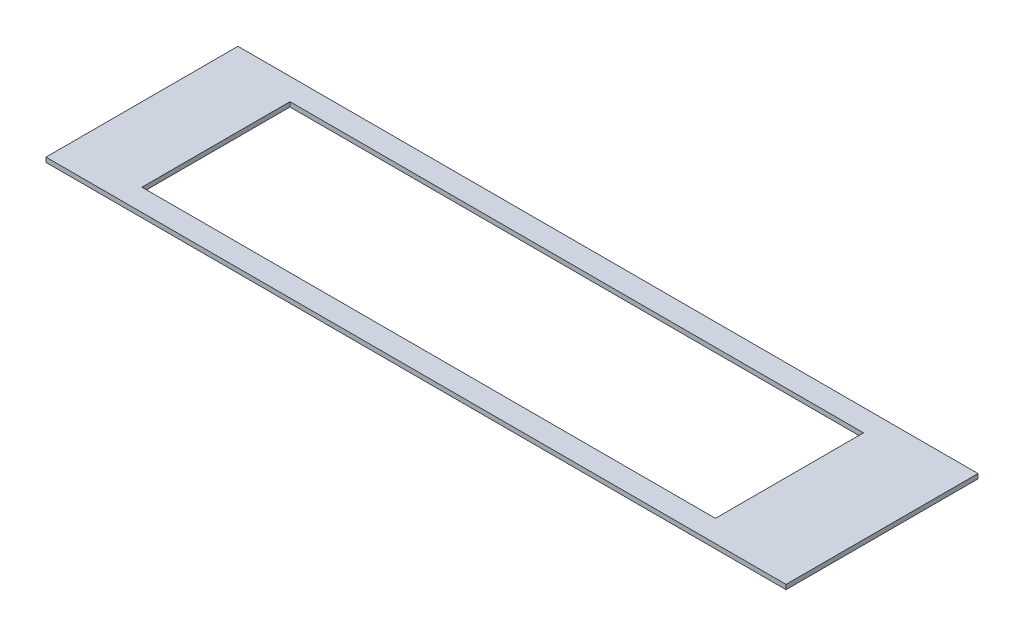
from build123d import *

# Parameters (mm, degrees)
SKETCH1_W           = 393.7
SKETCH1_H           = 101.6508
BOSS_EXTRUDE1_DEPTH = 3.175


with BuildPart() as part:
    # Sketch1 → Boss-Extrude1 (new body)
    with BuildSketch(Plane(origin=(0, 0, 0), x_dir=(1, 0, 0), z_dir=(0, 1, 0))):
        Polygon((254, 65.884425), (244.475, 65.884425), (-254, 65.884425), (-254, -65.884425), (244.475, -65.884425), (254, -65.884425), align=None)
        with Locations((-6.35, -0.0254)):
            Rectangle(SKETCH1_W, SKETCH1_H, mode=Mode.SUBTRACT)
    extrude(amount=BOSS_EXTRUDE1_DEPTH)


solid = part.part
